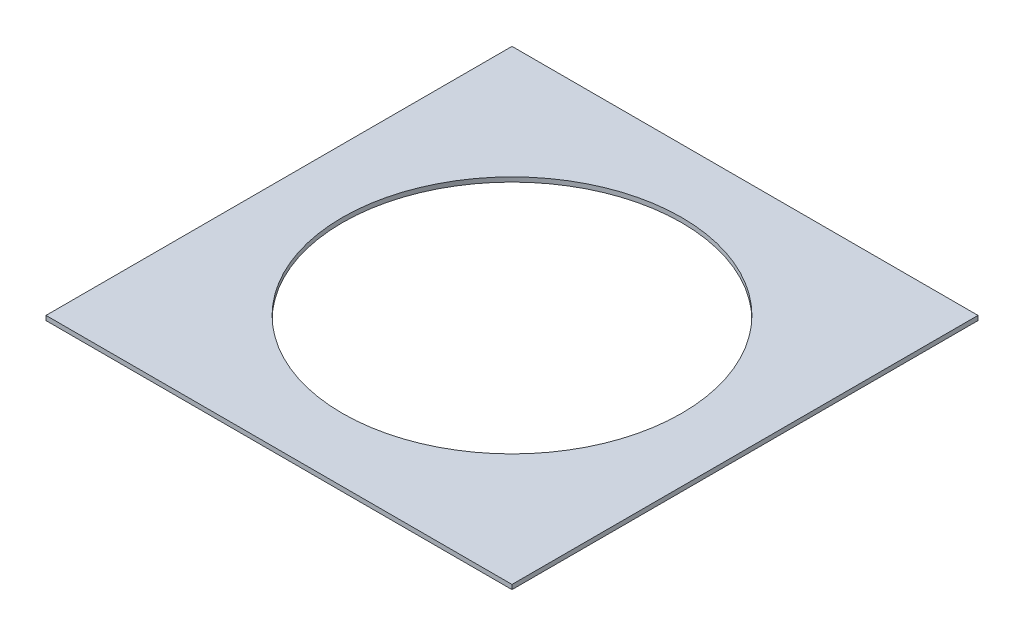
from build123d import *

# Parameters (mm, degrees)
SKETCH1_W           = 206
SKETCH1_H           = 206
SKETCH1_R           = 75
BOSS_EXTRUDE1_DEPTH = 2


with BuildPart() as part:
    # Sketch1 → Boss-Extrude1 (new body)
    with BuildSketch(Plane(origin=(0, 0, 0), x_dir=(1, 0, 0), z_dir=(0, 1, 0))):
        Rectangle(SKETCH1_W, SKETCH1_H)
        Circle(SKETCH1_R, mode=Mode.SUBTRACT)
    extrude(amount=BOSS_EXTRUDE1_DEPTH)


solid = part.part
